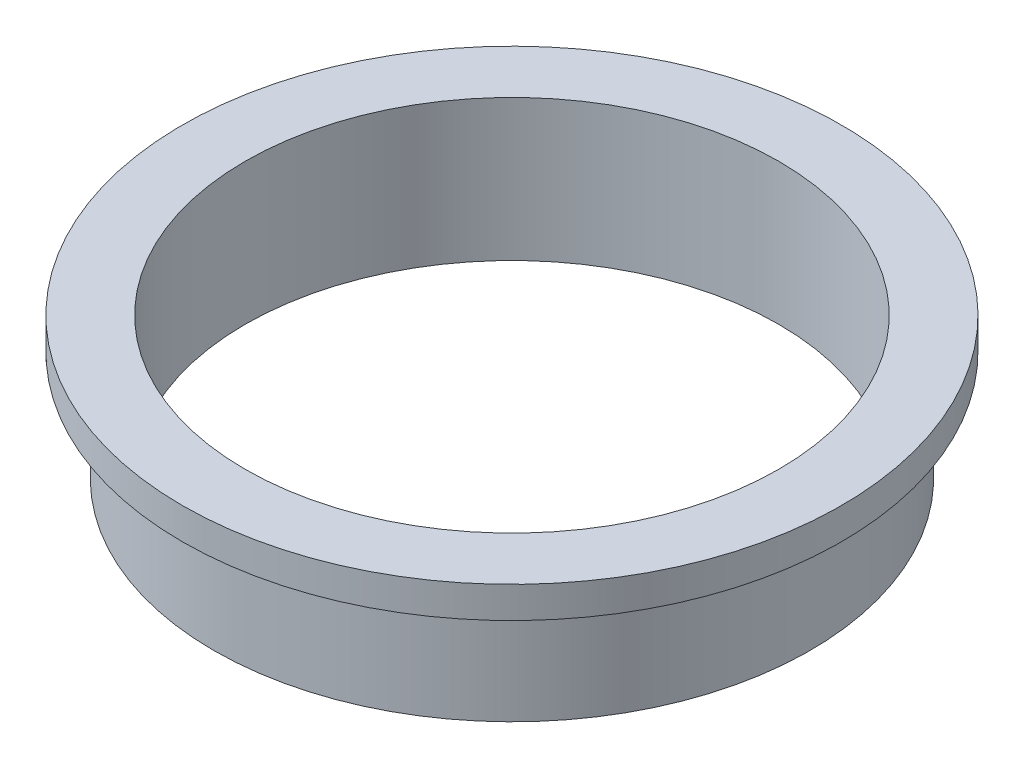
from build123d import *

# Parameters (mm, degrees)
CROQUIS1_R              = 9.5
CROQUIS1_R_2            = 8.5
SALIENTE_EXTRUIR1_DEPTH = 4.5
CROQUIS2_R              = 10.5
CROQUIS2_R_2            = 8.5
SALIENTE_EXTRUIR2_DEPTH = 1


with BuildPart() as part:
    # Croquis1 → Saliente-Extruir1 (new body)
    with BuildSketch(Plane(origin=(0, 0, 0), x_dir=(1, 0, 0), z_dir=(0, 1, 0))):
        Circle(CROQUIS1_R)
        Circle(CROQUIS1_R_2, mode=Mode.SUBTRACT)
    extrude(amount=SALIENTE_EXTRUIR1_DEPTH)

    # Croquis2 → Saliente-Extruir2 (add)
    with BuildSketch(Plane(origin=(0, 4.5, 0), x_dir=(1, 0, 0), z_dir=(0, 1, 0))):
        Circle(CROQUIS2_R)
        Circle(CROQUIS2_R_2, mode=Mode.SUBTRACT)
    extrude(amount=-SALIENTE_EXTRUIR2_DEPTH)


solid = part.part
